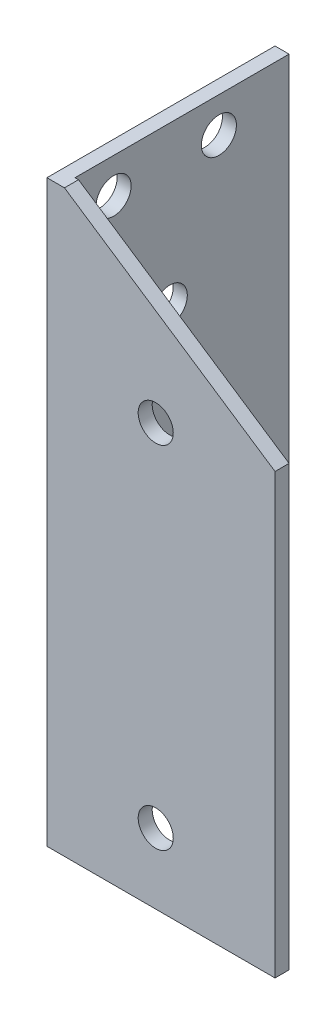
from build123d import *

# Parameters (mm, degrees)
EXTRUDE_1_DEPTH     = 165
SKETCH_2_R          = 5
CUT_EXTRUDE_1_DEPTH = 10
SKETCH_3_R          = 5
CUT_EXTRUDE_2_DEPTH = 10
CUT_EXTRUDE_3_DEPTH = 66


with BuildPart() as part:
    # Эскиз1 → Вытянуть-Тонкостенный1 (new body)
    with BuildSketch(Plane(origin=(0, 0, 0), x_dir=(1, 0, 0), z_dir=(0, 1, 0))):
        Polygon((0, 65), (0, 0), (65, 0), (65, 4), (4, 4), (4, 65), align=None)
    extrude(amount=EXTRUDE_1_DEPTH)

    # Эскиз2 → Вырез-Вытянуть1 (cut)
    with BuildSketch(Plane.XY):
        with Locations((31, 120)):
            Circle(SKETCH_2_R)
        with Locations((31, 20)):
            Circle(SKETCH_2_R)
    extrude(amount=-CUT_EXTRUDE_1_DEPTH, mode=Mode.SUBTRACT)

    # Эскиз3 → Вырез-Вытянуть2 (cut)
    with BuildSketch(Plane.ZY):
        with Locations((-31, 120)):
            Circle(SKETCH_3_R)
        with Locations((-31, 20)):
            Circle(SKETCH_3_R)
        with Locations((-15, 155)):
            Circle(SKETCH_3_R)
        with Locations((-45, 155)):
            Circle(SKETCH_3_R)
    extrude(amount=-CUT_EXTRUDE_2_DEPTH, mode=Mode.SUBTRACT)

    # Эскиз4 → Вырез-Вытянуть3 (cut, through all)
    with BuildSketch(Plane.XY):
        Polygon((5, 165), (65, 125), (65, 165), align=None)
    extrude(amount=-CUT_EXTRUDE_3_DEPTH, mode=Mode.SUBTRACT)


solid = part.part
